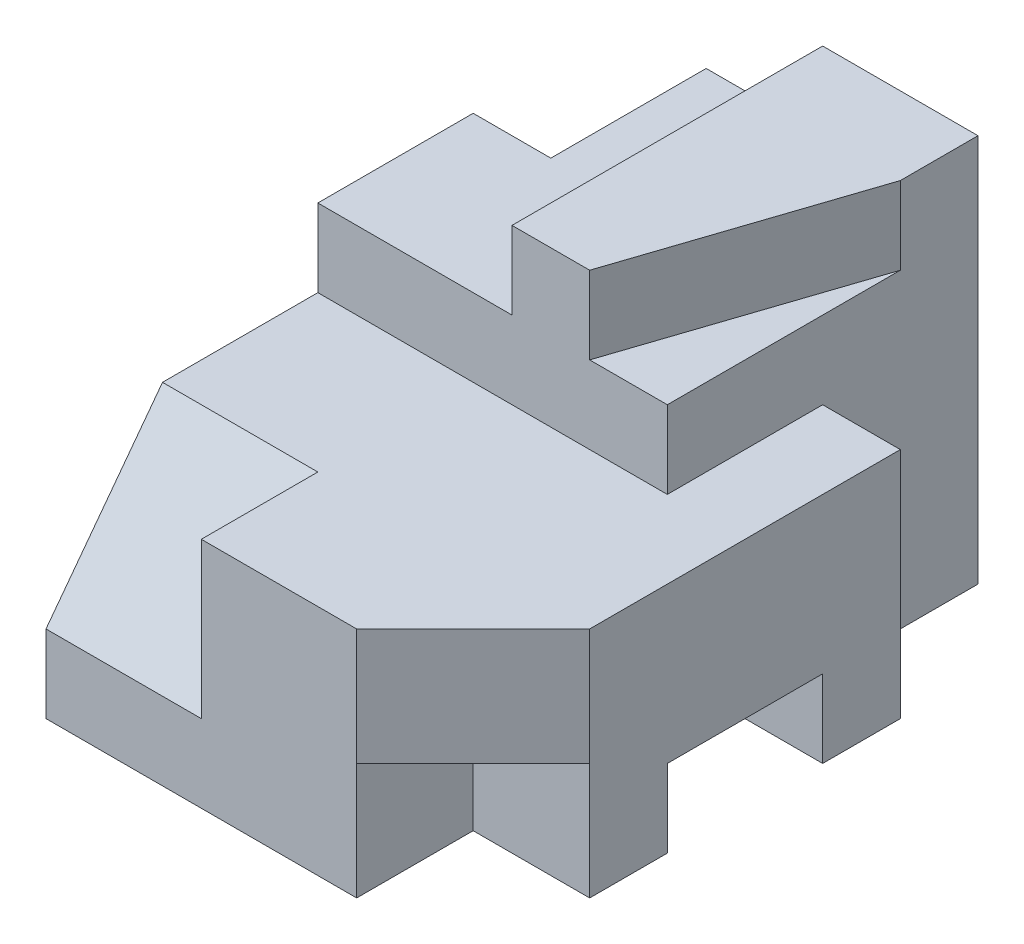
from build123d import *

# Parameters (mm, degrees)
SKETCH1_W           = 5.5
SKETCH1_H           = 5
BOSS_EXTRUDE1_DEPTH = 7.5
CUT_EXTRUDE1_DEPTH  = 2
CUT_EXTRUDE2_DEPTH  = 1
CUT_EXTRUDE3_DEPTH  = 2
CUT_EXTRUDE4_DEPTH  = 2
SKETCH6_W           = 2.5
SKETCH6_H           = 4
CUT_EXTRUDE5_DEPTH  = 1
SKETCH7_W           = 1
SKETCH7_H           = 2
CUT_EXTRUDE6_DEPTH  = 5
SKETCH8_W           = 2
SKETCH8_H           = 1
CUT_EXTRUDE7_DEPTH  = 6.5
CUT_EXTRUDE8_DEPTH  = 4
SKETCH11_W          = 1.5
SKETCH11_H          = 1.5
CUT_EXTRUDE9_DEPTH  = 1.5


with BuildPart() as part:
    # Sketch1 → Boss-Extrude1 (new body)
    with BuildSketch(Plane.XY):
        Rectangle(SKETCH1_W, SKETCH1_H)
    extrude(amount=BOSS_EXTRUDE1_DEPTH)

    # Sketch2 → Cut-Extrude1 (cut)
    with BuildSketch(Plane.ZY.offset(2.75)):
        Polygon((6, 2.5), (7.5, -1.5), (7.5, 2.5), align=None)
    extrude(amount=-CUT_EXTRUDE1_DEPTH, mode=Mode.SUBTRACT)

    # Sketch3 → Cut-Extrude2 (cut)
    with BuildSketch(Plane(origin=(2.75, 0, 0), x_dir=(0, 0, -1), z_dir=(1, 0, 0))):
        Polygon((0, -2.5), (-2, -2.5), (-2, 0.5), (-4, 0.5), (-4, 2.5), (0, 2.5), align=None)
    extrude(amount=-CUT_EXTRUDE2_DEPTH, mode=Mode.SUBTRACT)

    # Sketch4 → Cut-Extrude3 (cut)
    with BuildSketch(Plane(origin=(0, 2.5, 0), x_dir=(1, 0, 0), z_dir=(0, 1, 0))):
        Polygon((2.75, -7.5), (2.75, -4), (1.75, -4), (-2.75, -4), (-2.75, -6), (-0.75, -6), (-0.75, -7.5), align=None)
    extrude(amount=-CUT_EXTRUDE3_DEPTH, mode=Mode.SUBTRACT)

    # Sketch5 → Cut-Extrude4 (cut)
    with BuildSketch(Plane.ZY.offset(2.75)):
        Polygon((6, 2.5), (6, 0.5), (7.5, -1.5), align=None)
    extrude(amount=-CUT_EXTRUDE4_DEPTH, mode=Mode.SUBTRACT)

    # Sketch6 → Cut-Extrude5 (cut)
    with BuildSketch(Plane(origin=(0, 2.5, 0), x_dir=(1, 0, 0), z_dir=(0, 1, 0))):
        Polygon((1.75, -4), (1.75, -1), (0.75, -4), align=None)
        with Locations((-1.5, -2)):
            Rectangle(SKETCH6_W, SKETCH6_H)
    extrude(amount=-CUT_EXTRUDE5_DEPTH, mode=Mode.SUBTRACT)

    # Sketch7 → Cut-Extrude6 (cut, through all)
    with BuildSketch(Plane(origin=(0, 1.5, 0), x_dir=(1, 0, 0), z_dir=(0, 1, 0))):
        with Locations((-2.25, -1)):
            Rectangle(SKETCH7_W, SKETCH7_H)
    extrude(amount=-CUT_EXTRUDE6_DEPTH, mode=Mode.SUBTRACT)

    # Sketch8 → Cut-Extrude7 (cut, through all)
    with BuildSketch(Plane(origin=(2.75, 0, 0), x_dir=(0, 0, -1), z_dir=(1, 0, 0))):
        with Locations((-4, -2)):
            Rectangle(SKETCH8_W, SKETCH8_H)
    extrude(amount=-CUT_EXTRUDE7_DEPTH, mode=Mode.SUBTRACT)

    # Sketch10 → Cut-Extrude8 (cut, through all)
    with BuildSketch(Plane(origin=(0, 0.5, 0), x_dir=(1, 0, 0), z_dir=(0, 1, 0))):
        Polygon((2.75, -6), (1.25, -7.5), (2.75, -7.5), align=None)
    extrude(amount=-CUT_EXTRUDE8_DEPTH, mode=Mode.SUBTRACT)

    # Sketch11 → Cut-Extrude9 (cut)
    with BuildSketch(Plane(origin=(2.75, 0, 0), x_dir=(0, 0, -1), z_dir=(1, 0, 0))):
        with Locations((-6.75, -1.75)):
            Rectangle(SKETCH11_W, SKETCH11_H)
    extrude(amount=-CUT_EXTRUDE9_DEPTH, mode=Mode.SUBTRACT)


solid = part.part
